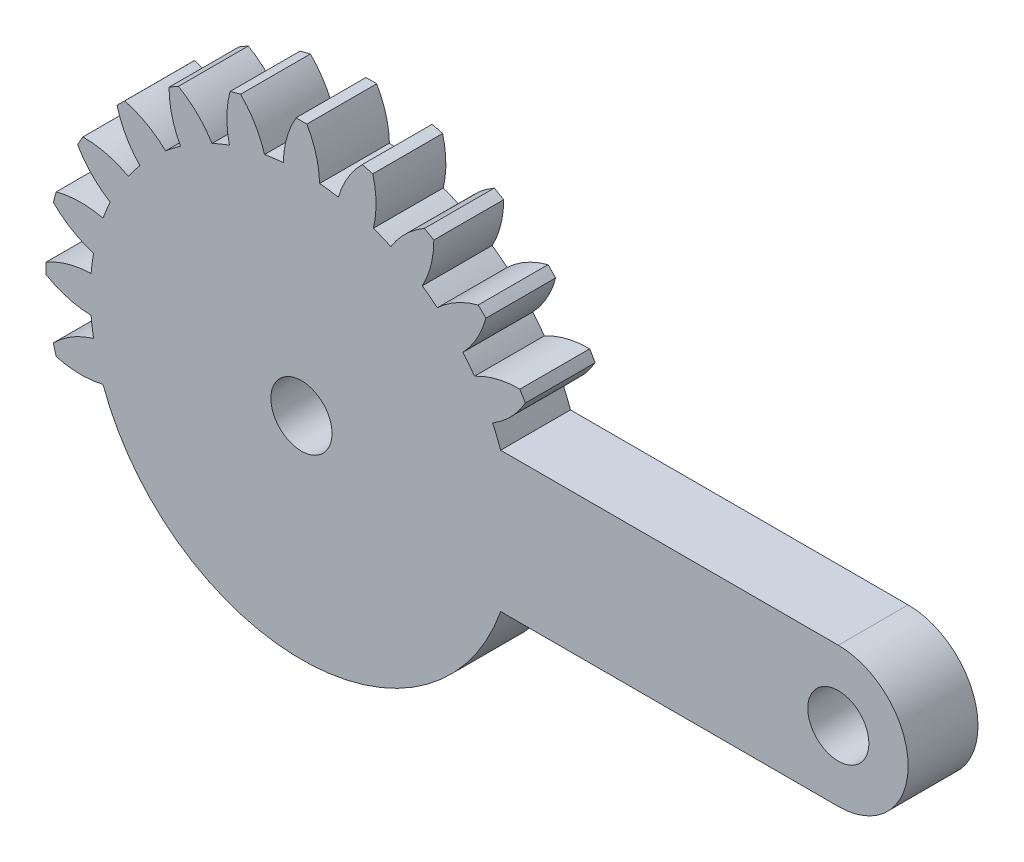
from build123d import *

# Parameters (mm, degrees)
ESQUISSE1_R        = 1.75
BOSS_EXTRU_1_DEPTH = 2


with BuildPart() as part:
    # Esquisse1 → Boss.-Extru.1 (new body, symmetric)
    with BuildSketch(Plane.XY):
        with BuildLine():
            ThreePointArc((30.75, -4), (34.75, 0), (30.75, 4))
            Line((30.75, 4), (11.409123542, 4))
            ThreePointArc((11.409123542, 4), (11.194344337, 4.566700654), (10.951436862, 5.12192646))
            ThreePointArc((10.951436862, 5.12192646), (12.008090957, 5.965388247), (12.82210701, 7.044889767))
            ThreePointArc((12.82210701, 7.044889767), (12.669951657, 7.315), (12.51210701, 7.581825517))
            ThreePointArc((12.51210701, 7.581825517), (11.170223244, 7.416617696), (9.911436862, 6.9232593))
            ThreePointArc((9.911436862, 6.9232593), (9.591641884, 7.359925677), (9.252623584, 7.781841479))
            ThreePointArc((9.252623584, 7.781841479), (10.05496909, 8.870045207), (10.561852666, 10.123446462))
            ThreePointArc((10.561852666, 10.123446462), (10.344972209, 10.344972209), (10.123446462, 10.561852666))
            ThreePointArc((10.123446462, 10.561852666), (8.870045207, 10.05496909), (7.781841479, 9.252623584))
            ThreePointArc((7.781841479, 9.252623584), (7.359925677, 9.591641884), (6.9232593, 9.911436862))
            ThreePointArc((6.9232593, 9.911436862), (7.416617696, 11.170223244), (7.581825517, 12.51210701))
            ThreePointArc((7.581825517, 12.51210701), (7.315, 12.669951657), (7.044889767, 12.82210701))
            ThreePointArc((7.044889767, 12.82210701), (5.965388247, 12.008090957), (5.12192646, 10.951436862))
            ThreePointArc((5.12192646, 10.951436862), (4.626642697, 11.169703548), (4.122086336, 11.365584201))
            ThreePointArc((4.122086336, 11.365584201), (4.272836063, 12.709169027), (4.085109489, 14.048088143))
            ThreePointArc((4.085109489, 14.048088143), (3.78652263, 14.131494839), (3.486235477, 14.208555951))
            ThreePointArc((3.486235477, 14.208555951), (2.654199937, 13.14288127), (2.112960617, 11.903927815))
            ThreePointArc((2.112960617, 11.903927815), (1.578061664, 11.986568374), (1.04, 12.04518576))
            ThreePointArc((1.04, 12.04518576), (0.837867713, 13.382005944), (0.31, 14.626715284))
            ThreePointArc((0.31, 14.626715284), (0, 14.63), (-0.31, 14.626715284))
            ThreePointArc((-0.31, 14.626715284), (-0.837867713, 13.382005944), (-1.04, 12.04518576))
            ThreePointArc((-1.04, 12.04518576), (-1.578061664, 11.986568374), (-2.112960617, 11.903927815))
            ThreePointArc((-2.112960617, 11.903927815), (-2.654199937, 13.14288127), (-3.486235477, 14.208555951))
            ThreePointArc((-3.486235477, 14.208555951), (-3.78652263, 14.131494839), (-4.085109489, 14.048088143))
            ThreePointArc((-4.085109489, 14.048088143), (-4.272836063, 12.709169027), (-4.122086336, 11.365584201))
            ThreePointArc((-4.122086336, 11.365584201), (-4.626642697, 11.169703548), (-5.12192646, 10.951436862))
            ThreePointArc((-5.12192646, 10.951436862), (-5.965388247, 12.008090957), (-7.044889767, 12.82210701))
            ThreePointArc((-7.044889767, 12.82210701), (-7.315, 12.669951657), (-7.581825517, 12.51210701))
            ThreePointArc((-7.581825517, 12.51210701), (-7.416617696, 11.170223244), (-6.9232593, 9.911436862))
            ThreePointArc((-6.9232593, 9.911436862), (-7.359925677, 9.591641884), (-7.781841479, 9.252623584))
            ThreePointArc((-7.781841479, 9.252623584), (-8.870045207, 10.05496909), (-10.123446462, 10.561852666))
            ThreePointArc((-10.123446462, 10.561852666), (-10.344972209, 10.344972209), (-10.561852666, 10.123446462))
            ThreePointArc((-10.561852666, 10.123446462), (-10.05496909, 8.870045207), (-9.252623584, 7.781841479))
            ThreePointArc((-9.252623584, 7.781841479), (-9.591641884, 7.359925677), (-9.911436862, 6.9232593))
            ThreePointArc((-9.911436862, 6.9232593), (-11.170223244, 7.416617696), (-12.51210701, 7.581825517))
            ThreePointArc((-12.51210701, 7.581825517), (-12.669951657, 7.315), (-12.82210701, 7.044889767))
            ThreePointArc((-12.82210701, 7.044889767), (-12.008090957, 5.965388247), (-10.951436862, 5.12192646))
            ThreePointArc((-10.951436862, 5.12192646), (-11.169703548, 4.626642697), (-11.365584201, 4.122086336))
            ThreePointArc((-11.365584201, 4.122086336), (-12.709169027, 4.272836063), (-14.048088143, 4.085109489))
            ThreePointArc((-14.048088143, 4.085109489), (-14.131494839, 3.78652263), (-14.208555951, 3.486235477))
            ThreePointArc((-14.208555951, 3.486235477), (-13.14288127, 2.654199937), (-11.903927815, 2.112960617))
            ThreePointArc((-11.903927815, 2.112960617), (-11.986568374, 1.578061664), (-12.04518576, 1.04))
            ThreePointArc((-12.04518576, 1.04), (-13.382005944, 0.837867713), (-14.626715284, 0.31))
            ThreePointArc((-14.626715284, 0.31), (-14.63, 0), (-14.626715284, -0.31))
            ThreePointArc((-14.626715284, -0.31), (-13.382005944, -0.837867713), (-12.04518576, -1.04))
            ThreePointArc((-12.04518576, -1.04), (-11.986568374, -1.578061664), (-11.903927815, -2.112960617))
            ThreePointArc((-11.903927815, -2.112960617), (-13.14288127, -2.654199937), (-14.208555951, -3.486235477))
            ThreePointArc((-14.208555951, -3.486235477), (-14.131494839, -3.78652263), (-14.048088143, -4.085109489))
            ThreePointArc((-14.048088143, -4.085109489), (-12.709169027, -4.272836063), (-11.365584201, -4.122086336))
            ThreePointArc((-11.365584201, -4.122086336), (0.064808849, -12.089826294), (11.409123542, -4))
            Line((11.409123542, -4), (30.75, -4))
        make_face()
        with Locations((30.75, 0)):
            Circle(ESQUISSE1_R, mode=Mode.SUBTRACT)
        Circle(ESQUISSE1_R, mode=Mode.SUBTRACT)
    extrude(amount=BOSS_EXTRU_1_DEPTH, both=True)


solid = part.part
